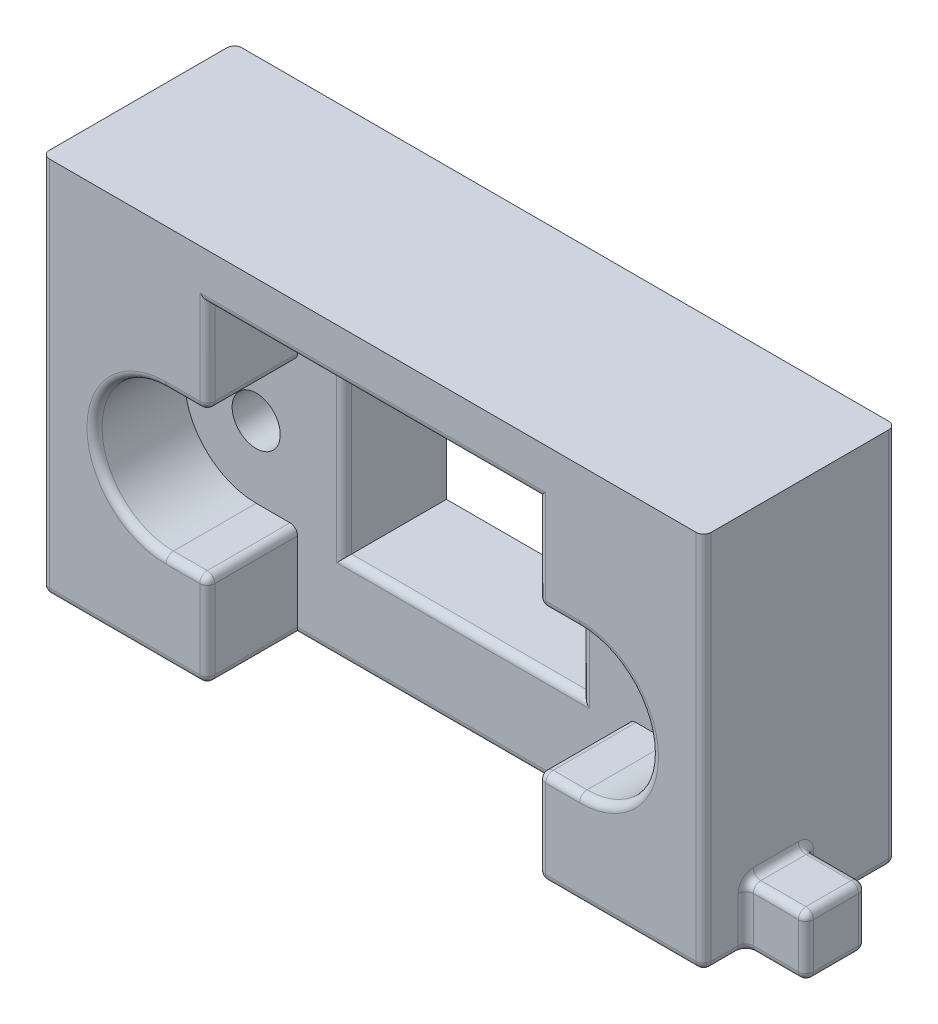
from build123d import *

# Parameters (mm, degrees)
SKETCH1_W           = 44
SKETCH1_H           = 25.2
SKETCH1_R           = 1.6
SKETCH1_W_2         = 15.8
SKETCH1_H_2         = 13.25
BOSS_EXTRUDE1_DEPTH = 6.8
BOSS_EXTRUDE4_DEPTH = 6
SKETCH6_W           = 4
SKETCH6_H           = 4
BOSS_EXTRUDE6_DEPTH = 4
FILLET1_R           = 0.5


with BuildPart() as part:
    # Sketch1 → Boss-Extrude1 (new body)
    with BuildSketch(Plane.XY):
        with Locations((0, 1.6)):
            Rectangle(SKETCH1_W, SKETCH1_H)
        with Locations((13.75, 0)):
            Circle(SKETCH1_R, mode=Mode.SUBTRACT)
        with Locations((0, 1.625)):
            Rectangle(SKETCH1_W_2, SKETCH1_H_2, mode=Mode.SUBTRACT)
        with Locations((-13.75, 0)):
            Circle(SKETCH1_R, mode=Mode.SUBTRACT)
    extrude(amount=-BOSS_EXTRUDE1_DEPTH)

    # Sketch1_3 → Boss-Extrude4 (add)
    with BuildSketch(Plane.XY):
        with BuildLine():
            Line((-11, 4.75), (-11, 11))
            Line((-11, 11), (11, 11))
            Line((11, 11), (11, 4.75))
            Line((11, 4.75), (13.75, 4.75))
            ThreePointArc((13.75, 4.75), (18.5, 0), (13.75, -4.75))
            Line((13.75, -4.75), (11, -4.75))
            Line((11, -4.75), (11, -11))
            Line((11, -11), (22, -11))
            Line((22, -11), (22, 14.2))
            Line((22, 14.2), (-22, 14.2))
            Line((-22, 14.2), (-22, -11))
            Line((-22, -11), (-11, -11))
            Line((-11, -11), (-11, -4.75))
            Line((-11, -4.75), (-13.75, -4.75))
            ThreePointArc((-13.75, -4.75), (-18.5, 0), (-13.75, 4.75))
            Line((-13.75, 4.75), (-11, 4.75))
        make_face()
    extrude(amount=BOSS_EXTRUDE4_DEPTH)

    # Sketch6 → Boss-Extrude6 (add)
    with BuildSketch(Plane(origin=(22, 0, 0), x_dir=(0, 0, -1), z_dir=(1, 0, 0))):
        with Locations((-1.2, -9)):
            Rectangle(SKETCH6_W, SKETCH6_H)
    extrude(amount=BOSS_EXTRUDE6_DEPTH)

    # Fillet1
    fillet1_edges = [part.edges().sort_by_distance(p)[0] for p in [
        (22, -7, 1.2),
        (24, -11, 3.2),
        (24, -11, -0.8),
        (26, -9, -0.8),
        (24, -7, -0.8),
        (22, -9, -0.8),
        (24, -7, 3.2),
        (22, -9, 3.2),
        (26, -9, 3.2),
        (26, -7, 1.2),
        (26, -11, 1.2),
        (22, 1.6, 6),
        (22, -11, 4.6),
        (22, -11, -3.8),
        (-22, 1.6, 6),
        (-22, -11, -0.4),
        (0, -11, -6.8),
        (22, 1.6, -6.8),
        (-22, 1.6, -6.8),
        (-12.375, 4.75, 6),
        (-18.5, 0, 6),
        (12.375, -4.75, 6),
        (18.5, 0, 6),
        (-7.9, 1.625, 0),
        (0, -5, 0),
        (7.9, 1.625, 0),
        (0, 8.25, 0),
        (-16.5, -11, 6),
        (16.5, -11, 6),
        (-11, 7.875, 6),
        (-12.375, -4.75, 6),
        (-11, -7.875, 6),
        (11, -7.875, 6),
        (12.375, 4.75, 6),
        (11, 7.875, 6),
        (0, 11, 6),
        (11, -4.75, 3),
        (-11, -4.75, 3),
        (-11, 4.75, 3),
        (11, 4.75, 3),
        (-11, -11, 3),
        (0, -11, 0),
        (11, -11, 3),
    ]]
    fillet(fillet1_edges, radius=FILLET1_R)


solid = part.part
